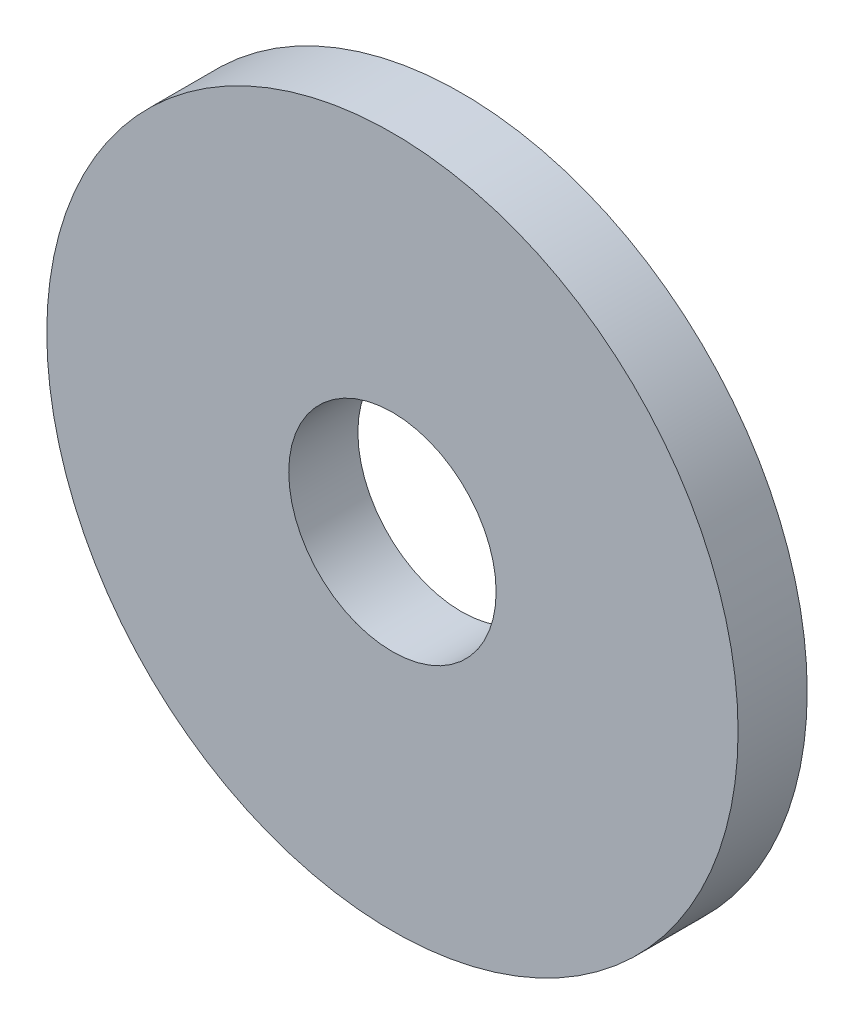
from build123d import *

# Parameters (mm, degrees)
ESQUISSE1_R        = 5
ESQUISSE1_R_2      = 1.5
BOSS_EXTRU_1_DEPTH = 1


with BuildPart() as part:
    # Esquisse1 → Boss.-Extru.1 (new body)
    with BuildSketch(Plane.XY):
        Circle(ESQUISSE1_R)
        Circle(ESQUISSE1_R_2, mode=Mode.SUBTRACT)
    extrude(amount=BOSS_EXTRU_1_DEPTH)


solid = part.part
